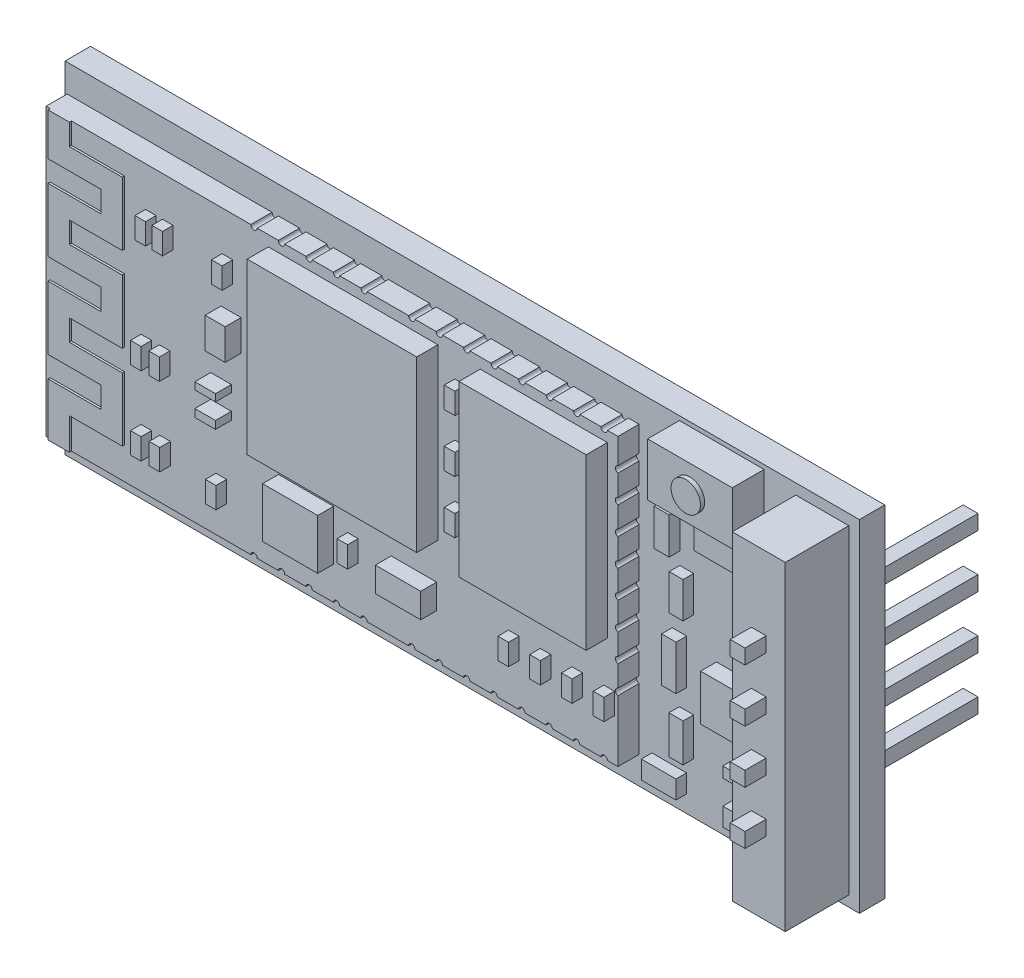
from build123d import *

# Parameters (mm, degrees)
SKETCH1_W                  = 37.5
SKETCH1_H                  = 16.1
BOSS_EXTRUDE1_DEPTH        = 1.2
SKETCH2_W                  = 2.5
SKETCH2_H                  = 15.1
BOSS_EXTRUDE2_DEPTH        = 3
SKETCH3_W                  = 0.7
SKETCH3_H                  = 0.7
BOSS_EXTRUDE3_DEPTH        = 1
BOSS_EXTRUDE3_DEPTH_BACK   = 10
BOSS_EXTRUDE3_2_DEPTH      = 1
BOSS_EXTRUDE3_2_DEPTH_BACK = 10
BOSS_EXTRUDE3_3_DEPTH      = 1
BOSS_EXTRUDE3_3_DEPTH_BACK = 10
BOSS_EXTRUDE3_4_DEPTH      = 1
BOSS_EXTRUDE3_4_DEPTH_BACK = 10
SKETCH10_W                 = 27
SKETCH10_H                 = 13.5
BOSS_EXTRUDE10_DEPTH       = 1
BOSS_EXTRUDE11_DEPTH       = 0.1
SKETCH12_W                 = 4
SKETCH12_H                 = 2.5
BOSS_EXTRUDE12_DEPTH       = 1.5
SKETCH13_R                 = 0.693604575
BOSS_EXTRUDE13_DEPTH       = 0.2
SKETCH14_W                 = 6
SKETCH14_H                 = 8
SKETCH14_W_2               = 8
BOSS_EXTRUDE14_DEPTH       = 1
SKETCH15_W                 = 0.5
SKETCH15_H                 = 1
BOSS_EXTRUDE15_DEPTH       = 0.5
SKETCH16_W                 = 0.5
SKETCH16_H                 = 1
BOSS_EXTRUDE16_DEPTH       = 0.5
SKETCH17_W                 = 2.602430281
SKETCH17_H                 = 2.367545487
SKETCH17_W_2               = 2.141321068
SKETCH17_H_2               = 1.16646021
SKETCH17_W_3               = 0.976073465
SKETCH17_H_3               = 0.365909355
SKETCH17_H_4               = 0.334632026
SKETCH17_W_4               = 0.943360629
SKETCH17_H_5               = 1.46024084
BOSS_EXTRUDE17_DEPTH       = 0.75
SKETCH18_W                 = 2.706810909
SKETCH18_H                 = 1.742911909
SKETCH18_W_2               = 0.716474489
SKETCH18_H_2               = 1.726632447
SKETCH18_W_3               = 0.652791749
SKETCH18_H_3               = 1.693765047
SKETCH18_W_4               = 0.684633119
SKETCH18_H_4               = 2.106353334
SKETCH18_W_5               = 0.668712434
SKETCH18_H_5               = 1.80079444
SKETCH18_W_6               = 1.634021616
SKETCH18_H_6               = 0.862411809
SKETCH18_W_7               = 1.353405455
SKETCH18_H_7               = 0.499412084
SKETCH18_W_8               = 1.368285393
SKETCH18_H_8               = 0.823617913
SKETCH18_H_9               = 0.791721171
BOSS_EXTRUDE18_DEPTH       = 0.5
SKETCH19_W                 = 3.051168615
SKETCH19_H                 = 2.165639046
BOSS_EXTRUDE19_DEPTH       = 0.75
CUT_EXTRUDE1_DEPTH         = 1
CUT_EXTRUDE2_DEPTH         = 1


with BuildPart() as part:
    # Sketch1 → Boss-Extrude1 (new body)
    with BuildSketch(Plane.XY):
        with Locations((18.75, 8.05)):
            Rectangle(SKETCH1_W, SKETCH1_H)
    extrude(amount=BOSS_EXTRUDE1_DEPTH)

    # Sketch2 → Boss-Extrude2 (add)
    with BuildSketch(Plane.XY.offset(1.2)):
        with Locations((35.75, 8.05)):
            Rectangle(SKETCH2_W, SKETCH2_H)
    extrude(amount=BOSS_EXTRUDE2_DEPTH)

    # Sketch10 → Boss-Extrude10 (add)
    with BuildSketch(Plane.XY.offset(1.2)):
        with Locations((13.6, 8.05)):
            Rectangle(SKETCH10_W, SKETCH10_H)
    extrude(amount=BOSS_EXTRUDE10_DEPTH)

    # Sketch11 → Boss-Extrude11 (add)
    with BuildSketch(Plane.XY.offset(2.2)):
        Polygon((0.3, 1.3), (0.3, 3.8), (2.8, 3.8), (2.8, 4.8), (0.3, 4.8), (0.3, 7.8), (2.8, 7.8), (2.8, 8.8), (0.3, 8.8), (0.3, 11.8), (2.8, 11.8), (2.8, 12.8), (0.3, 12.8), (0.3, 14.8), (1.3, 14.8), (1.3, 13.8), (3.8, 13.8), (3.8, 10.8), (1.3, 10.8), (1.3, 9.8), (3.8, 9.8), (3.8, 6.8), (1.3, 6.8), (1.3, 5.8), (3.8, 5.8), (3.8, 2.8), (1.3, 2.8), (1.3, 1.3), align=None)
    extrude(amount=BOSS_EXTRUDE11_DEPTH)



with BuildPart() as body_2:
    # Sketch3 → Boss-Extrude3 (new, two sides)
    with BuildSketch(Plane.XY.offset(4.2)) as boss_extrude3_sk:
        with Locations((35.75, 4.3)):
            Rectangle(SKETCH3_W, SKETCH3_H)
    extrude(amount=BOSS_EXTRUDE3_DEPTH)
    extrude(boss_extrude3_sk.sketch, amount=-BOSS_EXTRUDE3_DEPTH_BACK)


with BuildPart() as body_3:
    # Sketch3 → Boss-Extrude3 2 (new, two sides)
    with BuildSketch(Plane.XY.offset(4.2)) as boss_extrude3_2_sk:
        with Locations((35.75, 6.8)):
            Rectangle(SKETCH3_W, SKETCH3_H)
    extrude(amount=BOSS_EXTRUDE3_2_DEPTH)
    extrude(boss_extrude3_2_sk.sketch, amount=-BOSS_EXTRUDE3_2_DEPTH_BACK)


with BuildPart() as body_4:
    # Sketch3 → Boss-Extrude3 3 (new, two sides)
    with BuildSketch(Plane.XY.offset(4.2)) as boss_extrude3_3_sk:
        with Locations((35.75, 11.8)):
            Rectangle(SKETCH3_W, SKETCH3_H)
    extrude(amount=BOSS_EXTRUDE3_3_DEPTH)
    extrude(boss_extrude3_3_sk.sketch, amount=-BOSS_EXTRUDE3_3_DEPTH_BACK)


with BuildPart() as body_5:
    # Sketch3 → Boss-Extrude3 4 (new, two sides)
    with BuildSketch(Plane.XY.offset(4.2)) as boss_extrude3_4_sk:
        with Locations((35.75, 9.3)):
            Rectangle(SKETCH3_W, SKETCH3_H)
    extrude(amount=BOSS_EXTRUDE3_4_DEPTH)
    extrude(boss_extrude3_4_sk.sketch, amount=-BOSS_EXTRUDE3_4_DEPTH_BACK)


with BuildPart() as body_6:
    # Sketch12 → Boss-Extrude12 (new body)
    with BuildSketch(Plane.XY.offset(1.2)):
        with Locations((31, 14.65)):
            Rectangle(SKETCH12_W, SKETCH12_H)
    extrude(amount=BOSS_EXTRUDE12_DEPTH)


with BuildPart() as part_1:
    add(part.part)

    add(body_6.part)  # Boss-Extrude13 merges body 6
    # Sketch13 → Boss-Extrude13 (add)
    with BuildSketch(Plane.XY.offset(2.7)):
        with Locations((31, 14.65)):
            Circle(SKETCH13_R)
    extrude(amount=BOSS_EXTRUDE13_DEPTH)

    # Sketch14 → Boss-Extrude14 (add)
    with BuildSketch(Plane.XY.offset(2.2)):
        with Locations((23.600429337, 10.3)):
            Rectangle(SKETCH14_W, SKETCH14_H)
        with Locations((14.600429337, 10.3)):
            Rectangle(SKETCH14_W_2, SKETCH14_H)
    extrude(amount=BOSS_EXTRUDE14_DEPTH)

    # Sketch15 → Boss-Extrude15 (add)
    with BuildSketch(Plane.XY.offset(2.2)):
        with Locations((5.05, 12.430030241)):
            Rectangle(SKETCH15_W, SKETCH15_H)
        with Locations((5.85, 12.430030241)):
            Rectangle(SKETCH15_W, SKETCH15_H)
        with Locations((8.665669621, 12.430030241)):
            Rectangle(SKETCH15_W, SKETCH15_H)
    extrude(amount=BOSS_EXTRUDE15_DEPTH)

    # Sketch16 → Boss-Extrude16 (add)
    with BuildSketch(Plane.XY.offset(2.2)):
        with Locations((4.838962256, 7.221997086)):
            Rectangle(SKETCH16_W, SKETCH16_H)
        with Locations((5.701638758, 7.221997086)):
            Rectangle(SKETCH16_W, SKETCH16_H)
        with Locations((4.838818901, 3.533540421)):
            Rectangle(SKETCH16_W, SKETCH16_H)
        with Locations((5.720100061, 3.533540421)):
            Rectangle(SKETCH16_W, SKETCH16_H)
        with Locations((8.374321984, 3.306212795)):
            Rectangle(SKETCH16_W, SKETCH16_H)
        with Locations((19.650429337, 12.8)):
            Rectangle(SKETCH16_W, SKETCH16_H)
        with Locations((19.650429337, 10.3)):
            Rectangle(SKETCH16_W, SKETCH16_H)
        with Locations((19.650429337, 7.8)):
            Rectangle(SKETCH16_W, SKETCH16_H)
        with Locations((26.685091813, 3.8)):
            Rectangle(SKETCH16_W, SKETCH16_H)
        with Locations((25.185091813, 3.8)):
            Rectangle(SKETCH16_W, SKETCH16_H)
        with Locations((23.685091813, 3.8)):
            Rectangle(SKETCH16_W, SKETCH16_H)
        with Locations((22.185091813, 3.8)):
            Rectangle(SKETCH16_W, SKETCH16_H)
        with Locations((14.590448244, 3.990810695)):
            Rectangle(SKETCH16_W, SKETCH16_H)
    extrude(amount=BOSS_EXTRUDE16_DEPTH)

    # Sketch17 → Boss-Extrude17 (add)
    with BuildSketch(Plane.XY.offset(2.2)):
        with Locations((12.376318164, 4.047967675)):
            Rectangle(SKETCH17_W, SKETCH17_H)
        with Locations((17.469520012, 3.979476737)):
            Rectangle(SKETCH17_W_2, SKETCH17_H_2)
        with Locations((8.364147087, 6.520171395)):
            Rectangle(SKETCH17_W_3, SKETCH17_H_3)
        with Locations((8.364147087, 7.631045899)):
            Rectangle(SKETCH17_W_3, SKETCH17_H_4)
        with Locations((8.835827401, 10.033036523)):
            Rectangle(SKETCH17_W_4, SKETCH17_H_5)
    extrude(amount=BOSS_EXTRUDE17_DEPTH)

    # Sketch18 → Boss-Extrude18 (add)
    with BuildSketch(Plane.XY.offset(1.2)):
        with Locations((31.553494099, 12.29905928)):
            Rectangle(SKETCH18_W, SKETCH18_H)
        with Locations((28.662605916, 11.435743057)):
            Rectangle(SKETCH18_W_2, SKETCH18_H_2)
        with Locations((29.347239034, 9.137191125)):
            Rectangle(SKETCH18_W_3, SKETCH18_H_3)
        with Locations((29.004922476, 6.207999371)):
            Rectangle(SKETCH18_W_4, SKETCH18_H_4)
        with Locations((29.339278692, 3.303381049)):
            Rectangle(SKETCH18_W_5, SKETCH18_H_5)
        with Locations((28.522267884, 1.231924795)):
            Rectangle(SKETCH18_W_6, SKETCH18_H_6)
        with Locations((32.230196826, 1.231924795)):
            Rectangle(SKETCH18_W_7, SKETCH18_H_6)
        with Locations((32.230196826, 3.053675007)):
            Rectangle(SKETCH18_W_7, SKETCH18_H_7)
        with Locations((32.704361967, 10.395882605)):
            Rectangle(SKETCH18_W_8, SKETCH18_H_8)
        with Locations((32.704361967, 8.686169187)):
            Rectangle(SKETCH18_W_8, SKETCH18_H_9)
    extrude(amount=BOSS_EXTRUDE18_DEPTH)

    # Sketch19 → Boss-Extrude19 (add)
    with BuildSketch(Plane.XY.offset(1.2)):
        with Locations((32.282514113, 5.823350592)):
            Rectangle(SKETCH19_W, SKETCH19_H)
    extrude(amount=BOSS_EXTRUDE19_DEPTH)

    # Sketch20 → Cut-Extrude1 (cut)
    with BuildSketch(Plane.XY.offset(2.2)):
        with BuildLine():
            Line((26.6, 14.8), (26.3, 14.8))
            ThreePointArc((26.3, 14.8), (26.45, 14.65), (26.6, 14.8))
        make_face()
        with BuildLine():
            Line((25.3, 14.8), (25.004468137, 14.8))
            ThreePointArc((25.004468137, 14.8), (25.152234068, 14.652234068), (25.3, 14.8))
        make_face()
        with BuildLine():
            Line((23.708936273, 14.8), (24.004468137, 14.8))
            ThreePointArc((24.004468137, 14.8), (23.856702205, 14.652234068), (23.708936273, 14.8))
        make_face()
        with BuildLine():
            Line((22.408936273, 14.8), (22.708936273, 14.8))
            ThreePointArc((22.708936273, 14.8), (22.558936273, 14.65), (22.408936273, 14.8))
        make_face()
        with BuildLine():
            Line((21.408936273, 14.8), (21.108936273, 14.8))
            ThreePointArc((21.108936273, 14.8), (21.258936273, 14.65), (21.408936273, 14.8))
        make_face()
        with BuildLine():
            Line((20.108936273, 14.8), (19.81340441, 14.8))
            ThreePointArc((19.81340441, 14.8), (19.961170341, 14.652234068), (20.108936273, 14.8))
        make_face()
        with BuildLine():
            Line((18.517872546, 14.8), (18.81340441, 14.8))
            ThreePointArc((18.81340441, 14.8), (18.665638478, 14.652234068), (18.517872546, 14.8))
        make_face()
        with BuildLine():
            Line((17.217872546, 14.8), (17.517872546, 14.8))
            ThreePointArc((17.517872546, 14.8), (17.367872546, 14.65), (17.217872546, 14.8))
        make_face()
        with BuildLine():
            Line((15.261871651, 14.8), (14.961871651, 14.8))
            ThreePointArc((14.961871651, 14.8), (15.111871651, 14.65), (15.261871651, 14.8))
        make_face()
        with BuildLine():
            Line((13.961871651, 14.8), (13.666339787, 14.8))
            ThreePointArc((13.666339787, 14.8), (13.814105719, 14.652234068), (13.961871651, 14.8))
        make_face()
        with BuildLine():
            Line((12.370807924, 14.8), (12.666339787, 14.8))
            ThreePointArc((12.666339787, 14.8), (12.518573856, 14.652234068), (12.370807924, 14.8))
        make_face()
        with BuildLine():
            Line((11.070807924, 14.8), (11.370807924, 14.8))
            ThreePointArc((11.370807924, 14.8), (11.220807924, 14.65), (11.070807924, 14.8))
        make_face()
        with BuildLine():
            Line((10.070807924, 14.8), (9.770807924, 14.8))
            ThreePointArc((9.770807924, 14.8), (9.920807924, 14.65), (10.070807924, 14.8))
        make_face()
        with BuildLine():
            Line((10.070807924, 1.3), (9.770807924, 1.3))
            ThreePointArc((9.770807924, 1.3), (9.920807924, 1.45), (10.070807924, 1.3))
        make_face()
        with BuildLine():
            Line((11.070807924, 1.3), (11.370807924, 1.3))
            ThreePointArc((11.370807924, 1.3), (11.220807924, 1.45), (11.070807924, 1.3))
        make_face()
        with BuildLine():
            Line((12.370807924, 1.3), (12.666339787, 1.3))
            ThreePointArc((12.666339787, 1.3), (12.518573856, 1.447765932), (12.370807924, 1.3))
        make_face()
        with BuildLine():
            Line((13.961871651, 1.3), (13.666339787, 1.3))
            ThreePointArc((13.666339787, 1.3), (13.814105719, 1.447765932), (13.961871651, 1.3))
        make_face()
        with BuildLine():
            Line((15.261871651, 1.3), (14.961871651, 1.3))
            ThreePointArc((14.961871651, 1.3), (15.111871651, 1.45), (15.261871651, 1.3))
        make_face()
        with BuildLine():
            Line((17.217872546, 1.3), (17.517872546, 1.3))
            ThreePointArc((17.517872546, 1.3), (17.367872546, 1.45), (17.217872546, 1.3))
        make_face()
        with BuildLine():
            Line((18.517872546, 1.3), (18.81340441, 1.3))
            ThreePointArc((18.81340441, 1.3), (18.665638478, 1.447765932), (18.517872546, 1.3))
        make_face()
        with BuildLine():
            Line((20.108936273, 1.3), (19.81340441, 1.3))
            ThreePointArc((19.81340441, 1.3), (19.961170341, 1.447765932), (20.108936273, 1.3))
        make_face()
        with BuildLine():
            Line((21.408936273, 1.3), (21.108936273, 1.3))
            ThreePointArc((21.108936273, 1.3), (21.258936273, 1.45), (21.408936273, 1.3))
        make_face()
        with BuildLine():
            Line((22.408936273, 1.3), (22.708936273, 1.3))
            ThreePointArc((22.708936273, 1.3), (22.558936273, 1.45), (22.408936273, 1.3))
        make_face()
        with BuildLine():
            Line((23.708936273, 1.3), (24.004468137, 1.3))
            ThreePointArc((24.004468137, 1.3), (23.856702205, 1.447765932), (23.708936273, 1.3))
        make_face()
        with BuildLine():
            Line((25.3, 1.3), (25.004468137, 1.3))
            ThreePointArc((25.004468137, 1.3), (25.152234068, 1.447765932), (25.3, 1.3))
        make_face()
        with BuildLine():
            Line((26.6, 1.3), (26.3, 1.3))
            ThreePointArc((26.3, 1.3), (26.45, 1.45), (26.6, 1.3))
        make_face()
    extrude(amount=-CUT_EXTRUDE1_DEPTH, mode=Mode.SUBTRACT)

    # Sketch21 → Cut-Extrude2 (cut)
    with BuildSketch(Plane.XY.offset(2.2)):
        with BuildLine():
            Line((27.1, 13.300479938), (27.1, 13.599833571))
            ThreePointArc((27.1, 13.599833571), (26.978735777, 13.450156754), (27.1, 13.300479938))
        make_face()
        with BuildLine():
            Line((27.1, 12.300479938), (27.1, 12.001126305))
            ThreePointArc((27.1, 12.001126305), (26.978735777, 12.150803122), (27.1, 12.300479938))
        make_face()
        with BuildLine():
            Line((27.1, 10.701772672), (27.1, 11.001126305))
            ThreePointArc((27.1, 11.001126305), (26.978735777, 10.851449489), (27.1, 10.701772672))
        make_face()
        with BuildLine():
            Line((27.1, 9.701772672), (27.1, 9.40241904))
            ThreePointArc((27.1, 9.40241904), (26.978735777, 9.552095856), (27.1, 9.701772672))
        make_face()
        with BuildLine():
            Line((27.1, 8.103065407), (27.1, 8.40241904))
            ThreePointArc((27.1, 8.40241904), (26.978735777, 8.252742223), (27.1, 8.103065407))
        make_face()
        with BuildLine():
            Line((27.1, 7.103065407), (27.1, 6.803711774))
            ThreePointArc((27.1, 6.803711774), (26.978735777, 6.953388591), (27.1, 7.103065407))
        make_face()
        with BuildLine():
            Line((27.1, 5.504358141), (27.1, 5.803711774))
            ThreePointArc((27.1, 5.803711774), (26.978735777, 5.654034958), (27.1, 5.504358141))
        make_face()
        with BuildLine():
            Line((27.1, 4.504358141), (27.1, 4.205004509))
            ThreePointArc((27.1, 4.205004509), (26.978735777, 4.354681325), (27.1, 4.504358141))
        make_face()
    extrude(amount=-CUT_EXTRUDE2_DEPTH, mode=Mode.SUBTRACT)


solid = Compound([body_2.part, body_3.part, body_4.part, body_5.part, part_1.part])
